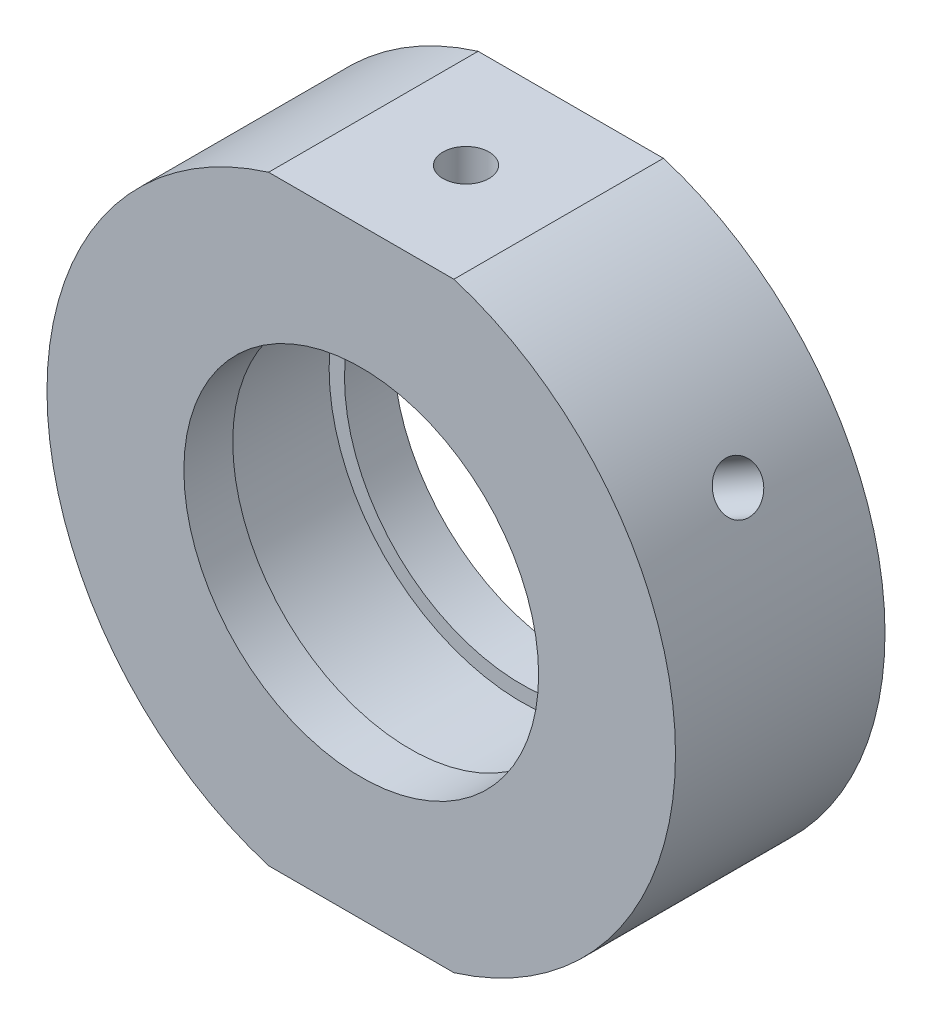
from build123d import *

# Parameters (mm, degrees)
SKETCH_2_W                       = 64.02174429
SKETCH_2_H                       = 9.248919907
CUT_EXTRUDE_1_DEPTH              = 49
HOLE_WIZARD_M4_2_D               = 3.3
HOLE_WIZARD_M4_2_DEPTH           = 5.5
HOLE_WIZARD_M4_2_TIP             = 0.991420021
HOLE_WIZARD_M6_2_D               = 5
HOLE_WIZARD_M6_2_DEPTH           = 5.5
HOLE_WIZARD_M6_2_TIP             = 1.502151548
HOLE_WIZARD_M4_3_D               = 3.3
HOLE_WIZARD_M4_3_DEPTH           = 13.4
HOLE_WIZARD_M4_3_TIP             = 0.991420021
HOLE_WIZARD_M4_3_ON_FACE_2_D     = 3.3
HOLE_WIZARD_M4_3_ON_FACE_2_DEPTH = 13.4
HOLE_WIZARD_M4_3_ON_FACE_2_TIP   = 0.991420021


with BuildPart() as part:
    # 草图1 → 旋转1 (revolve)
    with BuildSketch(Plane(origin=(0, 0, 0), x_dir=(1, 0, 0), z_dir=(0, 1, 0)), mode=Mode.PRIVATE) as revolve_1_sk:
        Polygon((22.5, 7.5), (22.5, -7.5), (12.7, -7.5), (12.7, -4), (13.8, -4), (13.8, 4), (12.7, 4), (12.7, 7.5), align=None)
    revolve(revolve_1_sk.sketch.rotate(Axis((0, 0, -31.9390681), (0, 0, 1)), 180), axis=Axis((0, 0, -31.9390681), (0, 0, 1)))  # turned: the seam where the file's is

    # 草图2 → 切除-拉伸1 (cut)
    with BuildSketch(Plane.XY.offset(7.5)):
        with Locations((-1.141100508, 26.124459954)):
            Rectangle(SKETCH_2_W, SKETCH_2_H)
        with Locations((-1.141100508, -26.124459954)):
            Rectangle(SKETCH_2_W, SKETCH_2_H)
    extrude(amount=-CUT_EXTRUDE_1_DEPTH, mode=Mode.SUBTRACT)

    # M4 螺纹孔2
    with Locations(Plane(origin=(0, 21.5, 0), x_dir=(1, 0, 0), z_dir=(0, 1, 0))):
        with Locations((0, 0)):
            Hole(HOLE_WIZARD_M4_2_D / 2, depth=HOLE_WIZARD_M4_2_DEPTH)
            with Locations((0, 0, -(HOLE_WIZARD_M4_2_DEPTH + HOLE_WIZARD_M4_2_TIP / 2))):  # 118° drill point
                Cone(0, HOLE_WIZARD_M4_2_D / 2, HOLE_WIZARD_M4_2_TIP, mode=Mode.SUBTRACT)

    # M6 螺纹孔2
    with Locations(Plane(origin=(0, -21.5, 0), x_dir=(-1, 0, 0), z_dir=(0, -1, 0))):
        with Locations((0, 0)):
            Hole(HOLE_WIZARD_M6_2_D / 2, depth=HOLE_WIZARD_M6_2_DEPTH)
            with Locations((0, 0, -(HOLE_WIZARD_M6_2_DEPTH + HOLE_WIZARD_M6_2_TIP / 2))):  # 118° drill point
                Cone(0, HOLE_WIZARD_M6_2_D / 2, HOLE_WIZARD_M6_2_TIP, mode=Mode.SUBTRACT)

    # M4 螺纹孔3
    with Locations(Plane(origin=(19.485571585, 11.25, 0), x_dir=(-0.5, 0.866025404, 0), z_dir=(0.866025404, 0.5, 0))):
        with Locations((0, 0)):
            Hole(HOLE_WIZARD_M4_3_D / 2, depth=HOLE_WIZARD_M4_3_DEPTH)
            with Locations((0, 0, -(HOLE_WIZARD_M4_3_DEPTH + HOLE_WIZARD_M4_3_TIP / 2))):  # 118° drill point
                Cone(0, HOLE_WIZARD_M4_3_D / 2, HOLE_WIZARD_M4_3_TIP, mode=Mode.SUBTRACT)

    # M4 螺纹孔3 on face 2
    with Locations(Plane(origin=(-19.485571585, 11.25, 0), x_dir=(-0.500000175, -0.866025303, 0), z_dir=(-0.866025303, 0.500000175, 0))):
        with Locations((0, 0)):
            Hole(HOLE_WIZARD_M4_3_ON_FACE_2_D / 2, depth=HOLE_WIZARD_M4_3_ON_FACE_2_DEPTH)
            with Locations((0, 0, -(HOLE_WIZARD_M4_3_ON_FACE_2_DEPTH + HOLE_WIZARD_M4_3_ON_FACE_2_TIP / 2))):  # 118° drill point
                Cone(0, HOLE_WIZARD_M4_3_ON_FACE_2_D / 2, HOLE_WIZARD_M4_3_ON_FACE_2_TIP, mode=Mode.SUBTRACT)


solid = part.part
